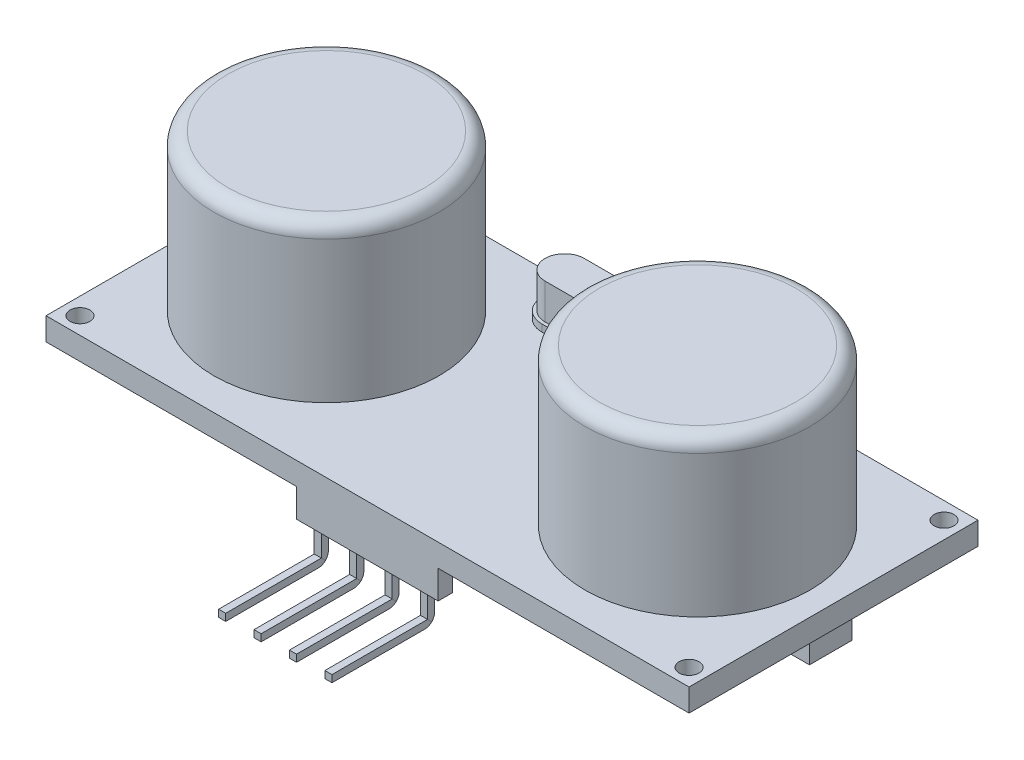
from build123d import *

# Parameters (mm, degrees)
CROQUIS1_W              = 45.4
CROQUIS1_H              = 20.4
SALIENTE_EXTRUIR1_DEPTH = 1.6
CROQUIS2_R              = 0.7
CORTAR_EXTRUIR1_DEPTH   = 1
SALIENTE_EXTRUIR2_DEPTH = 0.5
SALIENTE_EXTRUIR3_DEPTH = 3
CROQUIS9_R              = 7.95
SALIENTE_EXTRUIR4_DEPTH = 11
CROQUIS10_W             = 10
CROQUIS10_H             = 1
SALIENTE_EXTRUIR5_DEPTH = 2
CROQUIS12_W             = 0.5
CROQUIS12_H             = 0.5
REDONDEO4_R             = 0.7
MATRIZL1_COUNT          = 4
MATRIZL1_PITCH          = 2.5
REDONDEO5_R             = 1
CROQUIS13_W             = 9
CROQUIS13_H             = 3
SALIENTE_EXTRUIR6_DEPTH = 1.5
MATRIZL2_COUNT          = 2
MATRIZL2_PITCH          = 18
CROQUIS14_W             = 3
CROQUIS14_H             = 9
SALIENTE_EXTRUIR7_DEPTH = 1.5
REDONDEO6_R             = 0.7


with BuildPart() as part:
    # Croquis1 → Saliente-Extruir1 (new body)
    with BuildSketch(Plane(origin=(0, 0, 0), x_dir=(1, 0, 0), z_dir=(0, 1, 0))):
        Rectangle(CROQUIS1_W, CROQUIS1_H)
    extrude(amount=SALIENTE_EXTRUIR1_DEPTH)

    # Croquis2 → Cortar-Extruir1 (cut)
    with BuildSketch(Plane(origin=(0, 1.6, 0), x_dir=(1, 0, 0), z_dir=(0, 1, 0))):
        with Locations((-21.5, 9)):
            Circle(CROQUIS2_R)
        with Locations((21.5, 9)):
            Circle(CROQUIS2_R)
        with Locations((21.5, -9)):
            Circle(CROQUIS2_R)
        with Locations((-21.5, -9)):
            Circle(CROQUIS2_R)
    extrude(amount=-CORTAR_EXTRUIR1_DEPTH, mode=Mode.SUBTRACT)

    # Croquis3 → Saliente-Extruir2 (add)
    with BuildSketch(Plane(origin=(0, 1.6, 0), x_dir=(1, 0, 0), z_dir=(0, 1, 0))):
        with BuildLine():
            Line((-4.202221616, 9.535810589), (4.202221616, 9.535810589))
            ThreePointArc((4.202221616, 9.535810589), (5.818460699, 7.919571506), (4.202221616, 6.303332424))
            Line((4.202221616, 6.303332424), (-4.202221616, 6.303332424))
            ThreePointArc((-4.202221616, 6.303332424), (-5.818460699, 7.919571506), (-4.202221616, 9.535810589))
        make_face()
        with BuildLine():
            Line((-4.202221616, 9.304919292), (4.202221616, 9.304919292))
            ThreePointArc((4.202221616, 9.304919292), (5.587569401, 7.919571506), (4.202221616, 6.534223721))
            Line((4.202221616, 6.534223721), (-4.202221616, 6.534223721))
            ThreePointArc((-4.202221616, 6.534223721), (-5.587569401, 7.919571506), (-4.202221616, 9.304919292))
        make_face(mode=Mode.SUBTRACT)
    extrude(amount=SALIENTE_EXTRUIR2_DEPTH)

    # Croquis8 → Saliente-Extruir3 (add)
    with BuildSketch(Plane(origin=(0, 1.6, 0), x_dir=(1, 0, 0), z_dir=(0, 1, 0))):
        with BuildLine():
            Line((-4.202221616, 9.304919292), (4.202221616, 9.304919292))
            ThreePointArc((4.202221616, 9.304919292), (5.587569401, 7.919571506), (4.202221616, 6.534223721))
            Line((4.202221616, 6.534223721), (-4.202221616, 6.534223721))
            ThreePointArc((-4.202221616, 6.534223721), (-5.587569401, 7.919571506), (-4.202221616, 9.304919292))
        make_face()
    extrude(amount=SALIENTE_EXTRUIR3_DEPTH)

    # Croquis9 → Saliente-Extruir4 (add)
    with BuildSketch(Plane(origin=(0, 1.6, 0), x_dir=(1, 0, 0), z_dir=(0, 1, 0))):
        with Locations((-13.1, 0)):
            Circle(CROQUIS9_R)
        with Locations((13.1, 0)):
            Circle(CROQUIS9_R)
    extrude(amount=SALIENTE_EXTRUIR4_DEPTH)

    # Croquis10 → Saliente-Extruir5 (add)
    with BuildSketch(Plane.XZ):
        with Locations((-0.012747973, 9.7)):
            Rectangle(CROQUIS10_W, CROQUIS10_H)
    extrude(amount=SALIENTE_EXTRUIR5_DEPTH)

    # Barrer1: sweep along a curve in space
    with BuildLine() as barrer1_path:
        Line((-3.762747973, -2, 9.7), (-3.762747973, -4, 9.7))
        Line((-3.762747973, -4, 9.7), (-3.762747973, -4, 16.7))
    # Croquis12 → Barrer1 (sweep)
    with BuildSketch(Plane.XZ.offset(2)):
        with Locations((-3.762747973, 9.7)):
            Rectangle(CROQUIS12_W, CROQUIS12_H)
    barrer1 = sweep(path=barrer1_path.line, transition=Transition.RIGHT)

    # Redondeo4
    redondeo4_edges = [part.edges().sort_by_distance(p)[0] for p in [
        (-3.762747973, -4.25, 9.45),
    ]]
    fillet(redondeo4_edges, radius=REDONDEO4_R)

    # MatrizL1: Barrer1 ×4
    with Locations(*[(i * MATRIZL1_PITCH, 0, 0) for i in range(1, MATRIZL1_COUNT)]):
        add(barrer1)

    # Redondeo5
    redondeo5_edges = [part.edges().sort_by_distance(p)[0] for p in [
        (-21.05, 12.6, 0),
        (5.15, 12.6, 0),
    ]]
    fillet(redondeo5_edges, radius=REDONDEO5_R)

    # Croquis13 → Saliente-Extruir6 (add)
    with BuildSketch(Plane.XZ):
        Rectangle(CROQUIS13_W, CROQUIS13_H)
    saliente_extruir6 = extrude(amount=SALIENTE_EXTRUIR6_DEPTH)

    # MatrizL2: Saliente-Extruir6 ×2
    with Locations(*[(i * MATRIZL2_PITCH, 0, 0) for i in range(1, MATRIZL2_COUNT)]):
        add(saliente_extruir6)

    # Croquis14 → Saliente-Extruir7 (add)
    with BuildSketch(Plane.XZ):
        with Locations((-19.2, -0.292211089)):
            Rectangle(CROQUIS14_W, CROQUIS14_H)
    extrude(amount=SALIENTE_EXTRUIR7_DEPTH)

    # Redondeo6
    redondeo6_edges = [part.edges().sort_by_distance(p)[0] for p in [
        (-1.262747973, -4.25, 9.45),
        (1.237252027, -4.25, 9.45),
        (3.737252027, -4.25, 9.45),
    ]]
    fillet(redondeo6_edges, radius=REDONDEO6_R)


solid = part.part
